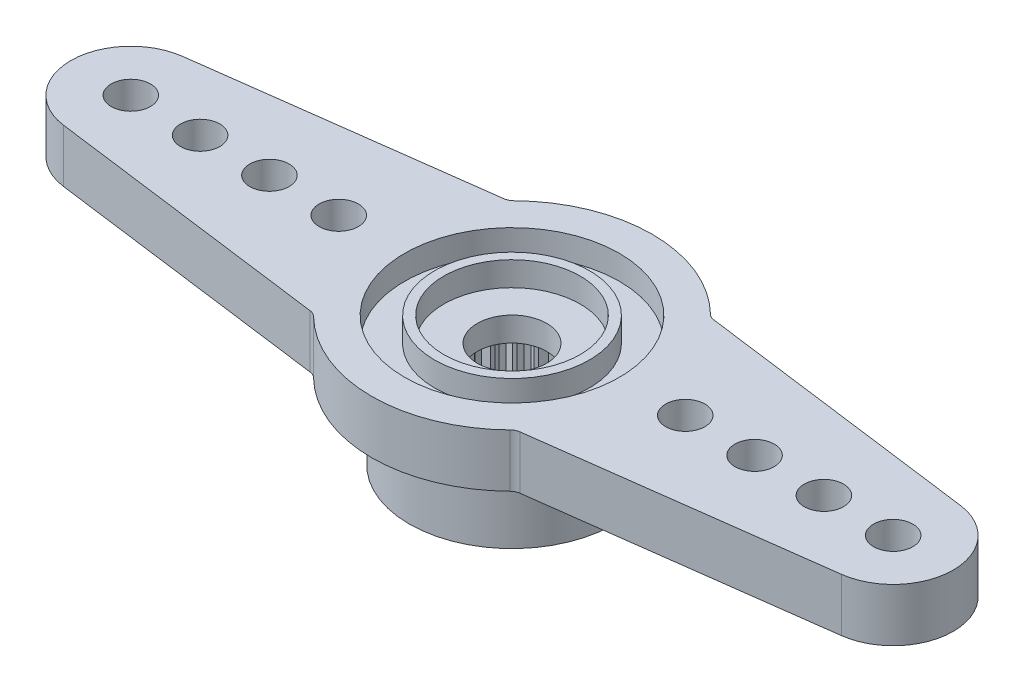
from build123d import *

# Parameters (mm, degrees)
ESQUISSE2_W                  = 4.45
ESQUISSE2_H                  = 5.6
ESQUISSE3_R                  = 0.85
BOSS_EXTRU_1_DEPTH           = 2.3
CONG_1_R                     = 0.5
ESQUISSE4_R                  = 2.95
ENL_V_MAT_EXTRU_1_DEPTH      = 1.05
ESQUISSE5_R                  = 4.65
ESQUISSE5_R_2                = 3.35
ENL_V_MAT_EXTRU_2_DEPTH      = 1.05
ESQUISSE6_R                  = 1.5
ENL_V_MAT_EXTRU_3_DEPTH      = 6.6
ESQUISSE8_R                  = 2.68
ENL_V_MAT_EXTRU_4_DEPTH      = 4.5
ENL_V_MAT_EXTRU_5_DEPTH      = 4.5
R_P_TITION_CIRCULAIRE1_COUNT = 25


with BuildPart() as part:
    # Esquisse2 → Révolution1 (revolve)
    with BuildSketch(Plane.XY):
        with Locations((-2.225, -0.7)):
            Rectangle(ESQUISSE2_W, ESQUISSE2_H)
    revolve(axis=Axis((0, 3.929571688, 0), (0, -1, 0)))

    # Esquisse3 → Boss.-Extru.1 (add)
    with BuildSketch(Plane(origin=(0, 2.1, 0), x_dir=(1, 0, 0), z_dir=(0, 1, 0))):
        with BuildLine():
            Line((-16.8393681, 2.57775664), (-4.370728284, 4.219284213))
            ThreePointArc((-4.370728284, 4.219284213), (0, 6.075), (4.370728284, 4.219284213))
            Line((4.370728284, 4.219284213), (16.8393681, 2.57775664))
            ThreePointArc((16.8393681, 2.57775664), (19.1, 0), (16.8393681, -2.57775664))
            Line((16.8393681, -2.57775664), (4.370728284, -4.219284213))
            ThreePointArc((4.370728284, -4.219284213), (0, -6.075), (-4.370728284, -4.219284213))
            Line((-4.370728284, -4.219284213), (-16.8393681, -2.57775664))
            ThreePointArc((-16.8393681, -2.57775664), (-19.1, 0), (-16.8393681, 2.57775664))
        make_face()
        with Locations((-16.5, 0)):
            Circle(ESQUISSE3_R, mode=Mode.SUBTRACT)
        with Locations((-13.5, 0)):
            Circle(ESQUISSE3_R, mode=Mode.SUBTRACT)
        with Locations((-10.5, 0)):
            Circle(ESQUISSE3_R, mode=Mode.SUBTRACT)
        with Locations((-7.5, 0)):
            Circle(ESQUISSE3_R, mode=Mode.SUBTRACT)
        with Locations((7.5, 0)):
            Circle(ESQUISSE3_R, mode=Mode.SUBTRACT)
        with Locations((10.5, 0)):
            Circle(ESQUISSE3_R, mode=Mode.SUBTRACT)
        with Locations((13.5, 0)):
            Circle(ESQUISSE3_R, mode=Mode.SUBTRACT)
        with Locations((16.5, 0)):
            Circle(ESQUISSE3_R, mode=Mode.SUBTRACT)
    extrude(amount=-BOSS_EXTRU_1_DEPTH)

    # Congé1
    cong_1_edges = [part.edges().sort_by_distance(p)[0] for p in [
        (-4.370728284, 0.95, -4.219284213),
        (4.370728284, 0.95, -4.219284213),
        (4.370728284, 0.95, 4.219284213),
        (-4.370728284, 0.95, 4.219284213),
    ]]
    fillet(cong_1_edges, radius=CONG_1_R)

    # Esquisse4 → Enlèv. mat.-Extru.1 (cut)
    with BuildSketch(Plane(origin=(0, 2.1, 0), x_dir=(1, 0, 0), z_dir=(0, 1, 0))):
        Circle(ESQUISSE4_R)
    extrude(amount=-ENL_V_MAT_EXTRU_1_DEPTH, mode=Mode.SUBTRACT)

    # Esquisse5 → Enlèv. mat.-Extru.2 (cut)
    with BuildSketch(Plane(origin=(0, 2.1, 0), x_dir=(1, 0, 0), z_dir=(0, 1, 0))):
        Circle(ESQUISSE5_R)
        Circle(ESQUISSE5_R_2, mode=Mode.SUBTRACT)
    extrude(amount=-ENL_V_MAT_EXTRU_2_DEPTH, mode=Mode.SUBTRACT)

    # Esquisse6 → Enlèv. mat.-Extru.3 (cut, through all)
    with BuildSketch(Plane.XZ.offset(3.5)):
        Circle(ESQUISSE6_R)
    extrude(amount=-ENL_V_MAT_EXTRU_3_DEPTH, mode=Mode.SUBTRACT)

    # Esquisse8 → Enlèv. mat.-Extru.4 (cut, through all)
    with BuildSketch(Plane(origin=(0, 0, 0), x_dir=(1, 0, 0), z_dir=(0, 1, 0))):
        Circle(ESQUISSE8_R)
    extrude(amount=-ENL_V_MAT_EXTRU_4_DEPTH, mode=Mode.SUBTRACT)

    # Esquisse9 → Enlèv. mat.-Extru.5 (cut, through all)
    with BuildSketch(Plane(origin=(0, 0, 0), x_dir=(1, 0, 0), z_dir=(0, 1, 0))):
        with BuildLine():
            Line((0.10528472, -3.048182266), (0.265600366, -2.666806413))
            ThreePointArc((0.265600366, -2.666806413), (0, -2.68), (-0.265600366, -2.666806413))
            Line((-0.265600366, -2.666806413), (-0.10528472, -3.048182266))
            ThreePointArc((-0.10528472, -3.048182266), (0, -3.05), (0.10528472, -3.048182266))
        make_face()
    enl_v_mat_extru_5 = extrude(amount=-ENL_V_MAT_EXTRU_5_DEPTH, mode=Mode.SUBTRACT)

    # Répétition circulaire1: Enlèv. mat.-Extru.5 ×25 about axis
    r_p_tition_circulaire1_axis = Axis((0, 0, 0), (0, 1, 0))
    for i in range(1, R_P_TITION_CIRCULAIRE1_COUNT):
        add(enl_v_mat_extru_5.rotate(r_p_tition_circulaire1_axis, i * 360 / R_P_TITION_CIRCULAIRE1_COUNT), mode=Mode.SUBTRACT)


solid = part.part
